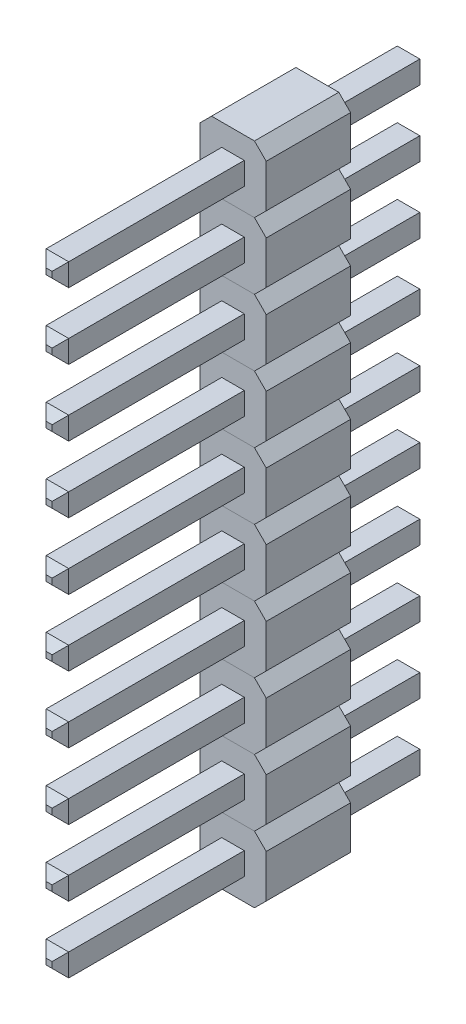
from build123d import *

# Parameters (mm, degrees)
PIN_DRAWING_W            = 0.678863608
PIN_DRAWING_H            = 0.678863608
BOSS_EXTRUDE1_DEPTH      = 2.54
SKETCH1_W                = 0.678863608
SKETCH1_H                = 0.678863608
BOSS_EXTRUDE2_DEPTH      = 5.5372
BOSS_EXTRUDE2_DEPTH_BACK = 5.5372
CHAMFER1_SIZE            = 0.25
LPATTERN2_COUNT          = 10
LPATTERN2_PITCH          = 2


with BuildPart() as part:
    # pin_drawing → Boss-Extrude1 (new body)
    with BuildSketch(Plane.XY):
        Polygon((-0.646446609, 1), (0.646446609, 1), (1, 0.646446609), (1, -0.646446609), (0.646446609, -1), (-0.646446609, -1), (-1, -0.646446609), (-1, 0.646446609), align=None)
        Rectangle(PIN_DRAWING_W, PIN_DRAWING_H, mode=Mode.SUBTRACT)
    extrude(amount=BOSS_EXTRUDE1_DEPTH)


with BuildPart() as body_2:
    # Sketch1 → Boss-Extrude2 (new body, two sides)
    with BuildSketch(Plane.XY.offset(2.54)) as boss_extrude2_sk:
        Rectangle(SKETCH1_W, SKETCH1_H)
    extrude(amount=BOSS_EXTRUDE2_DEPTH)
    extrude(boss_extrude2_sk.sketch, amount=-BOSS_EXTRUDE2_DEPTH_BACK)

    # Chamfer1
    chamfer1_edges = [body_2.edges().sort_by_distance(p)[0] for p in [
        (0, 0.339431804, -2.9972),
        (0, -0.339431804, 8.0772),
        (0.339431804, 0, 8.0772),
        (-0.339431804, 0, -2.9972),
        (0, 0.339431804, 8.0772),
        (-0.339431804, 0, 8.0772),
        (0, -0.339431804, -2.9972),
        (0.339431804, 0, -2.9972),
    ]]
    chamfer(chamfer1_edges, length=CHAMFER1_SIZE)


with BuildPart() as lpattern2_1:
    # LPattern2: pattern copy
    add(body_2.part.moved(Location(Vector(0, -1, 0) * (1 * LPATTERN2_PITCH))))


with BuildPart() as lpattern2_2:
    # LPattern2: pattern copy
    add(body_2.part.moved(Location(Vector(0, -1, 0) * (2 * LPATTERN2_PITCH))))


with BuildPart() as lpattern2_3:
    # LPattern2: pattern copy
    add(body_2.part.moved(Location(Vector(0, -1, 0) * (3 * LPATTERN2_PITCH))))


with BuildPart() as lpattern2_4:
    # LPattern2: pattern copy
    add(body_2.part.moved(Location(Vector(0, -1, 0) * (4 * LPATTERN2_PITCH))))


with BuildPart() as lpattern2_5:
    # LPattern2: pattern copy
    add(body_2.part.moved(Location(Vector(0, -1, 0) * (5 * LPATTERN2_PITCH))))


with BuildPart() as lpattern2_6:
    # LPattern2: pattern copy
    add(body_2.part.moved(Location(Vector(0, -1, 0) * (6 * LPATTERN2_PITCH))))


with BuildPart() as lpattern2_7:
    # LPattern2: pattern copy
    add(body_2.part.moved(Location(Vector(0, -1, 0) * (7 * LPATTERN2_PITCH))))


with BuildPart() as lpattern2_8:
    # LPattern2: pattern copy
    add(body_2.part.moved(Location(Vector(0, -1, 0) * (8 * LPATTERN2_PITCH))))


with BuildPart() as lpattern2_9:
    # LPattern2: pattern copy
    add(body_2.part.moved(Location(Vector(0, -1, 0) * (9 * LPATTERN2_PITCH))))


with BuildPart() as lpattern2_10:
    # LPattern2: pattern copy
    add(part.part.moved(Location(Vector(0, -1, 0) * (1 * LPATTERN2_PITCH))))


with BuildPart() as lpattern2_11:
    # LPattern2: pattern copy
    add(part.part.moved(Location(Vector(0, -1, 0) * (2 * LPATTERN2_PITCH))))


with BuildPart() as lpattern2_12:
    # LPattern2: pattern copy
    add(part.part.moved(Location(Vector(0, -1, 0) * (3 * LPATTERN2_PITCH))))


with BuildPart() as lpattern2_13:
    # LPattern2: pattern copy
    add(part.part.moved(Location(Vector(0, -1, 0) * (4 * LPATTERN2_PITCH))))


with BuildPart() as lpattern2_14:
    # LPattern2: pattern copy
    add(part.part.moved(Location(Vector(0, -1, 0) * (5 * LPATTERN2_PITCH))))


with BuildPart() as lpattern2_15:
    # LPattern2: pattern copy
    add(part.part.moved(Location(Vector(0, -1, 0) * (6 * LPATTERN2_PITCH))))


with BuildPart() as lpattern2_16:
    # LPattern2: pattern copy
    add(part.part.moved(Location(Vector(0, -1, 0) * (7 * LPATTERN2_PITCH))))


with BuildPart() as lpattern2_17:
    # LPattern2: pattern copy
    add(part.part.moved(Location(Vector(0, -1, 0) * (8 * LPATTERN2_PITCH))))


with BuildPart() as lpattern2_18:
    # LPattern2: pattern copy
    add(part.part.moved(Location(Vector(0, -1, 0) * (9 * LPATTERN2_PITCH))))


solid = Compound([part.part, body_2.part, lpattern2_1.part, lpattern2_2.part, lpattern2_3.part, lpattern2_4.part, lpattern2_5.part, lpattern2_6.part, lpattern2_7.part, lpattern2_8.part, lpattern2_9.part, lpattern2_10.part, lpattern2_11.part, lpattern2_12.part, lpattern2_13.part, lpattern2_14.part, lpattern2_15.part, lpattern2_16.part, lpattern2_17.part, lpattern2_18.part])
